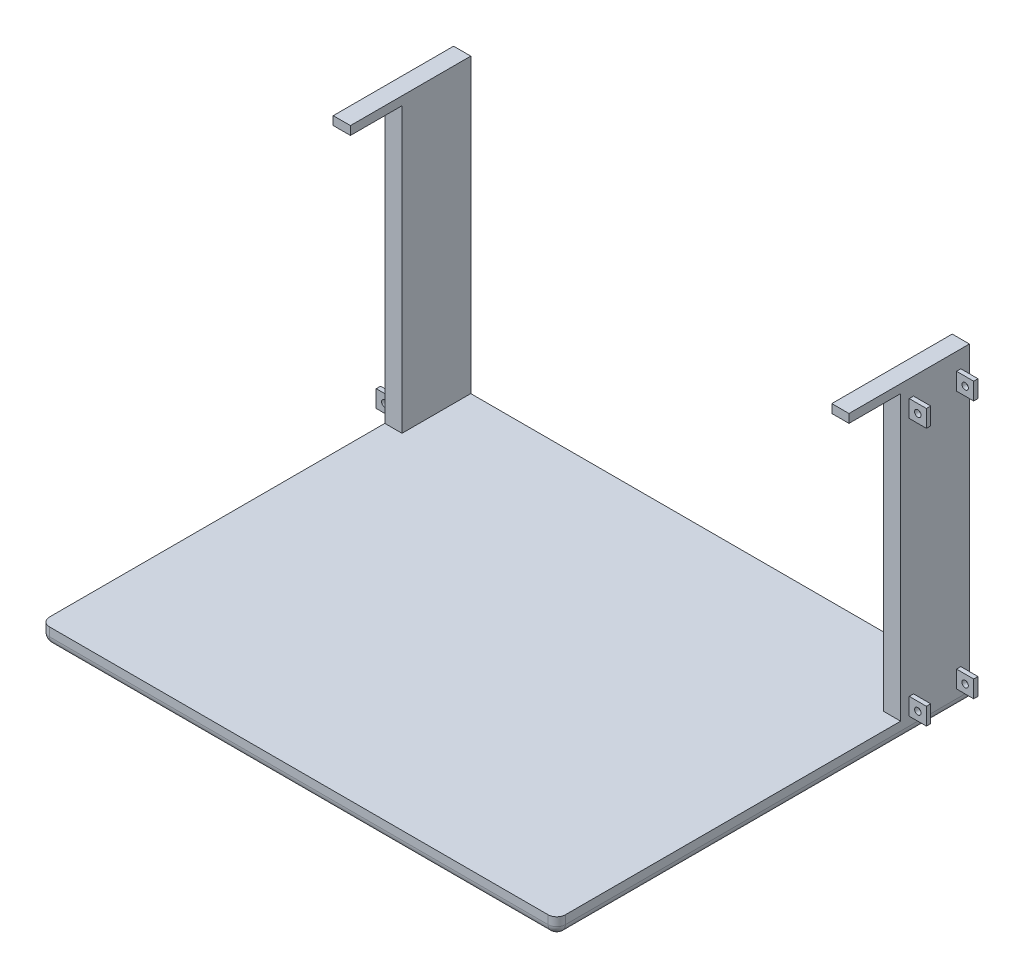
from build123d import *

# Parameters (mm, degrees)
SKETCH1_W                                      = 762
SKETCH1_H                                      = 381
BASE_STRUCTURE_DEPTH                           = 609.6
SKETCH3_W                                      = 711.2
SKETCH3_H                                      = 330.2
SHELL_CUT_DEPTH                                = 584.2
SKETCH5_W                                      = 25.4
SKETCH5_H                                      = 25.4
SKETCH5_R                                      = 4.7625
STABILITY_HOLDER_CUT_FOR_TOP_DEPTH             = 38.1
SKETCH7_W                                      = 63.5
SKETCH7_H                                      = 25.4
INSUDE_CUT_OF_STABILITY_HOLDERS_DEPTH          = 25.4
SKETCH14_W                                     = 711.2
SKETCH14_H                                     = 25.4
TOP_SHELLING_DEPTH                             = 406.4
SKETCH16_W                                     = 711.2
SKETCH16_H                                     = 50.8
BOTTOM_EXTENSION_DEPTH                         = 609.6
SKETCH16_6_W                                   = 711.2
SKETCH16_6_H                                   = 25.4
SKETCH16_6_H_2                                 = 50.8
BOTTOM_SHELLING_DEPTH                          = 584.2
SKETCH17_W                                     = 63.5
SKETCH17_H                                     = 25.4
BOTTOM_STABILTY_HOLDER_SHELL_CUT_DEPTH         = 25.4
SKETCH18_W                                     = 508
SKETCH18_H                                     = 406.4
F_3_4SHELL_FRONT_CHASSIS_CUT_DEPTH             = 763
FILLET_CORNER_OF_FRONT_CHASSIS_R               = 12.7
SKETCH95_W                                     = 508
SKETCH95_H                                     = 25.4
CUT_TOP_EXTRUSION_OF_CHASSIS_DEPTH             = 763
SKETCH171_W                                    = 76.290149759
SKETCH171_H                                    = 12.7
EXTRUSION_OF_STEERING_RACK_HOLDER_DEPTH        = 25.4
SKETCH172_W                                    = 76.2
SKETCH172_H                                    = 12.7
EXTRUSION_OF_OTHER_STEERING_RACK_HOLDER_DEPTH  = 25.4
MIRRORS_STABILITY_HOLDERS_COPY_1_SKETCH_W      = 25.4
MIRRORS_STABILITY_HOLDERS_COPY_1_SKETCH_H      = 25.4
MIRRORS_STABILITY_HOLDERS_COPY_1_SKETCH_R      = 4.7625
MIRRORS_STABILITY_HOLDERS_COPY_1_DEPTH         = 38.1
SKETCH173_W                                    = 63.5
SKETCH173_H                                    = 406.4
EXTRUSION_OF_OTHER_STABILITY_HOLDERS_TOP_DEPTH = 25.4
FILLET_OF_RIGHT_CORNER_OF_FRONT_CHASSIS_R      = 12.7
FILLET_OF_BOTTOM_SIDE_OF_FRONT_CHASSIS_R       = 12.7


with BuildPart() as part:
    # Sketch1 → Base Structure (new body)
    with BuildSketch(Plane.XY):
        with Locations((381, 190.5)):
            Rectangle(SKETCH1_W, SKETCH1_H)
    extrude(amount=-BASE_STRUCTURE_DEPTH)

    # Sketch3 → Shell Cut (cut)
    with BuildSketch(Plane(origin=(0, 0, -609.6), x_dir=(-1, 0, 0), z_dir=(0, 0, -1))):
        with Locations((-381, 190.5)):
            Rectangle(SKETCH3_W, SKETCH3_H)
    extrude(amount=-SHELL_CUT_DEPTH, mode=Mode.SUBTRACT)

    # Sketch5 → Stability Holder Cut for Top (add, symmetric)
    with BuildSketch(Plane.XY.offset(-558.8)):
        with Locations((774.7, 342.9)):
            Rectangle(SKETCH5_W, SKETCH5_H)
        with Locations((774.7, 342.9)):
            Circle(SKETCH5_R, mode=Mode.SUBTRACT)
    stability_holder_cut_for_top = extrude(amount=STABILITY_HOLDER_CUT_FOR_TOP_DEPTH, both=True)

    # Sketch7 → Insude Cut of Stability Holders (cut)
    with BuildSketch(Plane(origin=(787.4, 0, 0), x_dir=(0, 0, -1), z_dir=(1, 0, 0))):
        with Locations((558.8, 342.9)):
            Rectangle(SKETCH7_W, SKETCH7_H)
    extrude(amount=-INSUDE_CUT_OF_STABILITY_HOLDERS_DEPTH, mode=Mode.SUBTRACT)

    # Sketch14 → Top Shelling (cut)
    with BuildSketch(Plane(origin=(0, 0, -609.6), x_dir=(-1, 0, 0), z_dir=(0, 0, -1))):
        with Locations((-381, 368.3)):
            Rectangle(SKETCH14_W, SKETCH14_H)
    extrude(amount=-TOP_SHELLING_DEPTH, mode=Mode.SUBTRACT)

    # Sketch16 → Bottom Extension (add)
    with BuildSketch(Plane(origin=(0, 0, -609.6), x_dir=(-1, 0, 0), z_dir=(0, 0, -1))):
        Polygon((-736.6, -50.8), (-736.6, 0), (-762, 0), (-762, -76.2), (0, -76.2), (0, 0), (-25.4, 0), (-25.4, -50.8), align=None)
        with Locations((-381, -25.4)):
            Rectangle(SKETCH16_W, SKETCH16_H)
    extrude(amount=-BOTTOM_EXTENSION_DEPTH)

    # Sketch16_6 → Bottom Shelling (cut)
    with BuildSketch(Plane(origin=(0, 0, -609.6), x_dir=(-1, 0, 0), z_dir=(0, 0, -1))):
        with Locations((-381, 12.7)):
            Rectangle(SKETCH16_6_W, SKETCH16_6_H)
        with Locations((-381, -25.4)):
            Rectangle(SKETCH16_6_W, SKETCH16_6_H_2)
    extrude(amount=-BOTTOM_SHELLING_DEPTH, mode=Mode.SUBTRACT)

    # Mirror5: Stability Holder Cut for Top across plane
    add(stability_holder_cut_for_top.mirror(Plane.ZX.offset(152.4)))

    # Sketch17 → Bottom Stabilty Holder Shell Cut (cut)
    with BuildSketch(Plane(origin=(787.4, 0, 0), x_dir=(0, 0, -1), z_dir=(1, 0, 0))):
        with Locations((558.8, -38.1)):
            Rectangle(SKETCH17_W, SKETCH17_H)
    extrude(amount=-BOTTOM_STABILTY_HOLDER_SHELL_CUT_DEPTH, mode=Mode.SUBTRACT)

    # Sketch18 → 3_4Shell Front Chassis Cut (cut, through all)
    with BuildSketch(Plane(origin=(762, 0, 0), x_dir=(0, 0, -1), z_dir=(1, 0, 0))):
        with Locations((254, 152.4)):
            Rectangle(SKETCH18_W, SKETCH18_H)
    extrude(amount=-F_3_4SHELL_FRONT_CHASSIS_CUT_DEPTH, mode=Mode.SUBTRACT)

    # Fillet Corner of Front Chassis
    fillet_corner_of_front_chassis_edges = [part.edges().sort_by_distance(p)[0] for p in [
        (762, -63.5, 0),
    ]]
    fillet(fillet_corner_of_front_chassis_edges, radius=FILLET_CORNER_OF_FRONT_CHASSIS_R)

    # Sketch95 → Cut Top Extrusion of Chassis (cut, through all)
    with BuildSketch(Plane(origin=(762, 0, 0), x_dir=(0, 0, -1), z_dir=(1, 0, 0))):
        with Locations((254, 368.3)):
            Rectangle(SKETCH95_W, SKETCH95_H)
    extrude(amount=-CUT_TOP_EXTRUSION_OF_CHASSIS_DEPTH, mode=Mode.SUBTRACT)

    # Sketch171 → Extrusion of Steering Rack Holder (add)
    with BuildSketch(Plane(origin=(762, 0, 0), x_dir=(0, 0, -1), z_dir=(1, 0, 0))):
        with Locations((469.854925121, 374.65)):
            Rectangle(SKETCH171_W, SKETCH171_H)
    extrude(amount=-EXTRUSION_OF_STEERING_RACK_HOLDER_DEPTH)

    # Sketch172 → Extrusion of Other Steering Rack Holder (add)
    with BuildSketch(Plane.ZY):
        with Locations((-469.9, 374.65)):
            Rectangle(SKETCH172_W, SKETCH172_H)
    extrude(amount=-EXTRUSION_OF_OTHER_STEERING_RACK_HOLDER_DEPTH)

    # Mirrors Stability Holders: Stability Holder Cut for Top across plane
    add(stability_holder_cut_for_top.mirror(Plane(origin=(381, 0, 0), x_dir=(0, 0, 1), z_dir=(1, 0, 0))))

    # Mirrors Stability Holders copy 1 sketch → Mirrors Stability Holders copy 1 (add, symmetric)
    with BuildSketch(Plane(origin=(762, 304.8, -558.8), x_dir=(-1, 0, 0), z_dir=(0, 0, 1))):
        with Locations((774.7, 342.9)):
            Rectangle(MIRRORS_STABILITY_HOLDERS_COPY_1_SKETCH_W, MIRRORS_STABILITY_HOLDERS_COPY_1_SKETCH_H)
        with Locations((774.7, 342.9)):
            Circle(MIRRORS_STABILITY_HOLDERS_COPY_1_SKETCH_R, mode=Mode.SUBTRACT)
    extrude(amount=MIRRORS_STABILITY_HOLDERS_COPY_1_DEPTH, both=True)

    # Sketch173 → Extrusion of Other Stability Holders Top (cut)
    with BuildSketch(Plane.ZY.offset(25.4)):
        with Locations((-558.8, 152.4)):
            Rectangle(SKETCH173_W, SKETCH173_H)
    extrude(amount=-EXTRUSION_OF_OTHER_STABILITY_HOLDERS_TOP_DEPTH, mode=Mode.SUBTRACT)

    # Fillet of Right Corner of Front Chassis
    fillet_of_right_corner_of_front_chassis_edges = [part.edges().sort_by_distance(p)[0] for p in [
        (0, -63.5, 0),
    ]]
    fillet(fillet_of_right_corner_of_front_chassis_edges, radius=FILLET_OF_RIGHT_CORNER_OF_FRONT_CHASSIS_R)

    # Fillet of Bottom Side of Front Chassis
    fillet_of_bottom_side_of_front_chassis_edges = [part.edges().sort_by_distance(p)[0] for p in [
        (381, -76.2, 0),
        (762, -76.2, -311.15),
        (758.280256121, -76.2, -3.719743879),
        (0, -76.2, -311.15),
        (3.719743879, -76.2, -3.719743879),
    ]]
    fillet(fillet_of_bottom_side_of_front_chassis_edges, radius=FILLET_OF_BOTTOM_SIDE_OF_FRONT_CHASSIS_R)


solid = part.part
